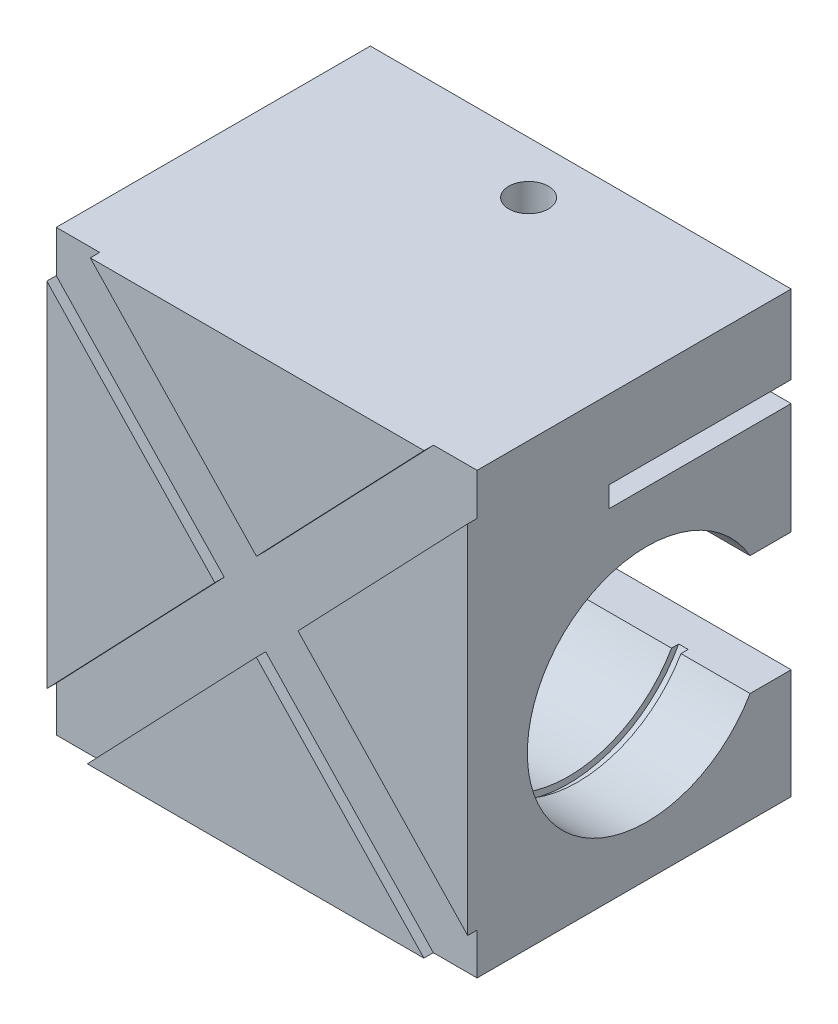
from build123d import *

# Parameters (mm, degrees)
BOSS_EXTRUDE1_DEPTH = 67
SKETCH2_R           = 20
CUT_EXTRUDE1_DEPTH  = 1.5
BOSS_EXTRUDE3_DEPTH = 1.5
SKETCH8_R           = 3.15
CUT_EXTRUDE2_DEPTH  = 12.5


with BuildPart() as part:
    # Sketch1 → Boss-Extrude1 (new body)
    with BuildSketch(Plane(origin=(0, 0, 0), x_dir=(0, 0, -1), z_dir=(1, 0, 0))):
        with BuildLine():
            Line((0, 70), (-50, 70))
            Line((-50, 70), (-50, 0))
            Line((-50, 0), (0, 0))
            Line((0, 0), (0, 17.5))
            Line((0, 17.5), (-6.545517328, 17.5))
            ThreePointArc((-6.545517328, 17.5), (-42, 27), (-6.545517328, 36.5))
            Line((-6.545517328, 36.5), (0, 36.5))
            Line((0, 36.5), (0, 54.2))
            Line((0, 54.2), (-29, 54.2))
            Line((-29, 54.2), (-29, 57.5))
            Line((-29, 57.5), (0, 57.5))
            Line((0, 57.5), (0, 70))
        make_face()
    extrude(amount=-BOSS_EXTRUDE1_DEPTH)

    # Sketch2 → Cut-Extrude1 (cut)
    with BuildSketch(Plane(origin=(-12.5, 0, 0), x_dir=(0, 0, -1), z_dir=(1, 0, 0))):
        with Locations((-23, 27)):
            Circle(SKETCH2_R)
    cut_extrude1 = extrude(amount=CUT_EXTRUDE1_DEPTH, mode=Mode.SUBTRACT)

    # Mirror1: Cut-Extrude1 across plane
    add(cut_extrude1.mirror(Plane(origin=(-33.5, 0, 0), x_dir=(0, 0, 1), z_dir=(1, 0, 0))), mode=Mode.SUBTRACT)

    # Sketch7 → Boss-Extrude3 (add)
    with BuildSketch(Plane.XY.offset(50)):
        Polygon((-60.553250223, 0), (-6.967587392, 0), (-33.650176709, 28.153479174), align=None)
        Polygon((0, 6.603562983), (0, 63.367654561), (-27.0098942, 35.102389871), align=None)
        Polygon((-67, 63.341726624), (-67, 7.149153864), (-40.262049953, 35.129834934), align=None)
        Polygon((-6.940604727, 70), (-60.084264634, 70), (-33.621767444, 42.078745631), align=None)
    extrude(amount=BOSS_EXTRUDE3_DEPTH)

    # Sketch8 → Cut-Extrude2 (cut)
    with BuildSketch(Plane(origin=(0, 70, 0), x_dir=(1, 0, 0), z_dir=(0, 1, 0))):
        with Locations((-33.5, -8.3)):
            Circle(SKETCH8_R)
    extrude(amount=-CUT_EXTRUDE2_DEPTH, mode=Mode.SUBTRACT)


solid = part.part
